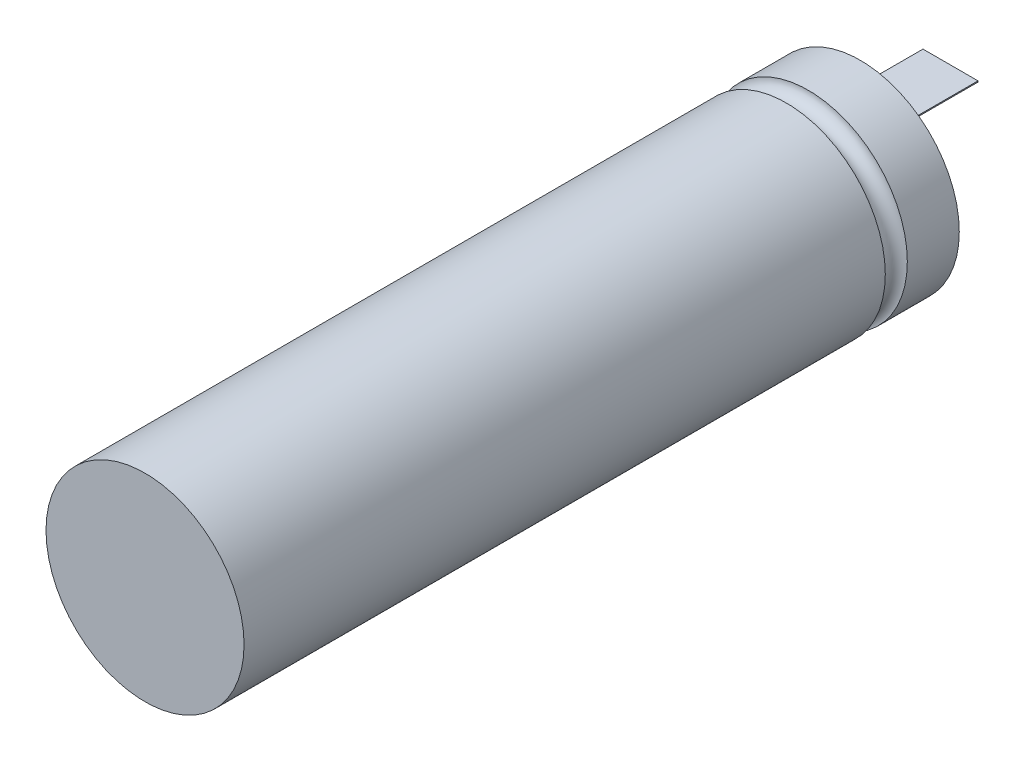
from build123d import *

# Parameters (mm, degrees)
SKETCH_2_R      = 9
EXTRUDE_1_DEPTH = 32.5
SKETCH_3_R      = 1
SHELL_1_T       = -0.2
SKETCH_4_W      = 5
SKETCH_4_H      = 0.1
EXTRUDE_2_DEPTH = 73


with BuildPart() as part:
    # 草图2 → 凸台-拉伸1 (new, symmetric)
    with BuildSketch(Plane.XY):
        Circle(SKETCH_2_R)
    extrude(amount=EXTRUDE_1_DEPTH, both=True)

    # 草图3 → 切除-旋转1 (revolve, cut)
    with BuildSketch(Plane(origin=(0, 0, 0), x_dir=(1, 0, 0), z_dir=(0, 1, 0)), mode=Mode.PRIVATE) as cut_revolve_1_sk:
        with Locations((-9, 26.776971268)):
            Circle(SKETCH_3_R)
    revolve(cut_revolve_1_sk.sketch.rotate(Axis((0, 0, 0), (0, 0, -1)), 180), axis=Axis((0, 0, 0), (0, 0, -1)), mode=Mode.SUBTRACT)

    # 抽壳1
    shell_1_openings = [part.faces().sort_by_distance(p)[0] for p in [
        (0, 0, -32.5),
    ]]
    offset(amount=SHELL_1_T, openings=shell_1_openings, kind=Kind.INTERSECTION)

    # 草图4 → 凸台-拉伸2 (add)
    with BuildSketch(Plane(origin=(0, 0, 32.3), x_dir=(-1, 0, 0), z_dir=(0, 0, -1))):
        with Locations((0, 4.473785882)):
            Rectangle(SKETCH_4_W, SKETCH_4_H)
    extrude(amount=EXTRUDE_2_DEPTH)


solid = part.part
